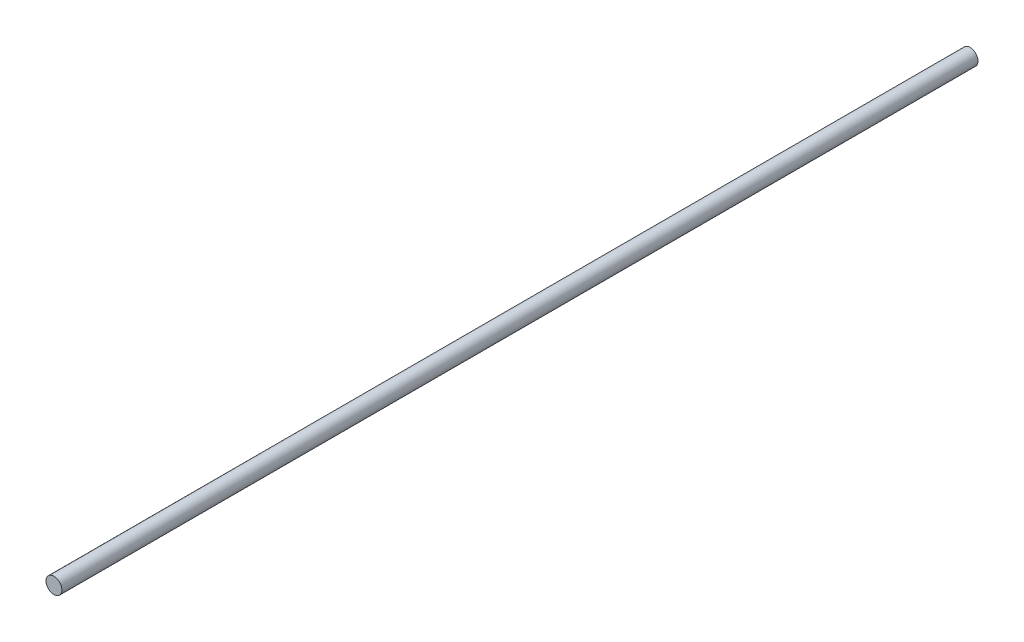
from build123d import *

# Parameters (mm, degrees)
SKETCH1_R           = 0.65
BOSS_EXTRUDE1_DEPTH = 75


with BuildPart() as part:
    # Sketch1 → Boss-Extrude1 (new body)
    with BuildSketch(Plane.XY):
        Circle(SKETCH1_R)
    extrude(amount=BOSS_EXTRUDE1_DEPTH)


solid = part.part
